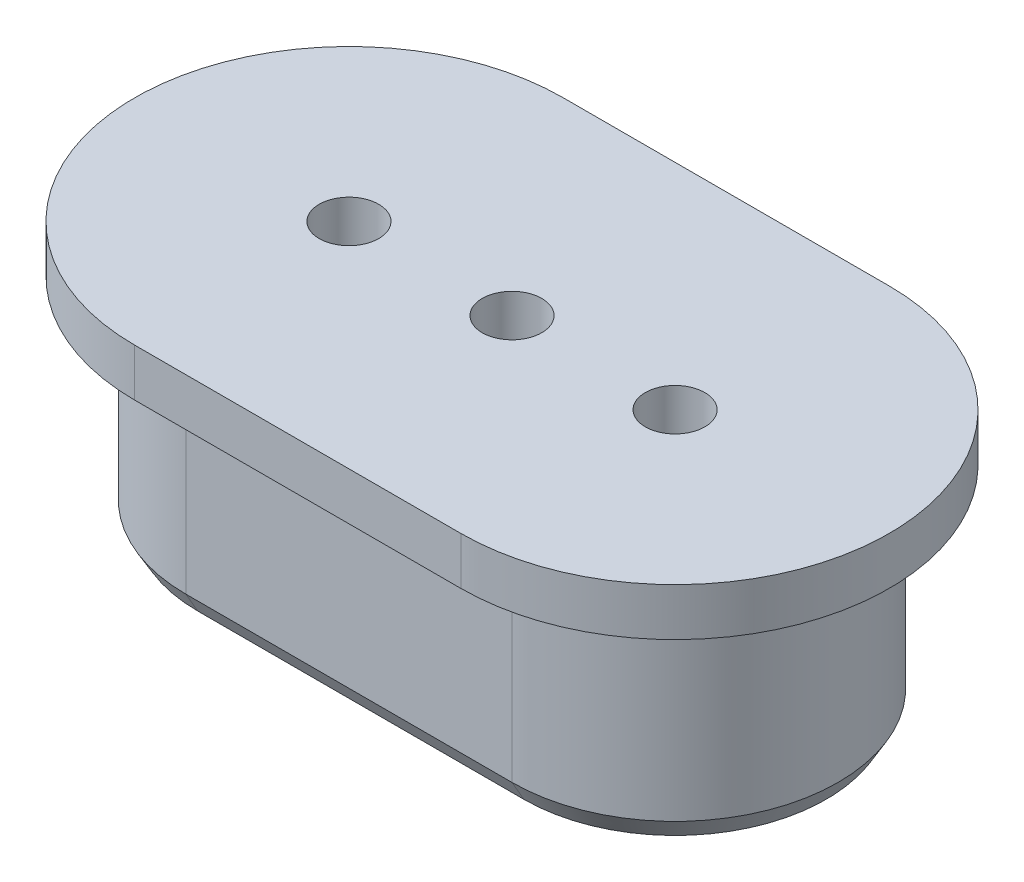
from build123d import *

# Parameters (mm, degrees)
BOSS_EXTRUDE1_DEPTH     = 4.5
SKETCH2_R               = 0.625
BOSS_EXTRUDE2_DEPTH     = 1
CHAMFER2_SIZE           = 0.25
CHAMFER2_SIZE2          = 0.433012702
SKETCH3_R               = 0.625
CUT_EXTRUDE1_DEPTH      = 1
CUT_EXTRUDE1_DEPTH_BACK = 6.5


with BuildPart() as part:
    # Sketch1 → Boss-Extrude1 (new body)
    with BuildSketch(Plane(origin=(0, 0, 0), x_dir=(1, 0, 0), z_dir=(0, 1, 0))):
        with BuildLine():
            Line((-3.425, 3.425), (3.425, 3.425))
            ThreePointArc((3.425, 3.425), (6.85, 0), (3.425, -3.425))
            Line((3.425, -3.425), (-3.425, -3.425))
            ThreePointArc((-3.425, -3.425), (-6.85, 0), (-3.425, 3.425))
        make_face()
        with BuildLine():
            Line((-3.425, 2.925), (3.425, 2.925))
            ThreePointArc((3.425, 2.925), (6.35, 0), (3.425, -2.925))
            Line((3.425, -2.925), (-3.425, -2.925))
            ThreePointArc((-3.425, -2.925), (-6.35, 0), (-3.425, 2.925))
        make_face(mode=Mode.SUBTRACT)
    extrude(amount=BOSS_EXTRUDE1_DEPTH)

    # Sketch2 → Boss-Extrude2 (add)
    with BuildSketch(Plane(origin=(0, 4.5, 0), x_dir=(1, 0, 0), z_dir=(0, 1, 0))):
        with BuildLine():
            Line((-3.425, 4.5), (3.425, 4.5))
            ThreePointArc((3.425, 4.5), (7.925, 0), (3.425, -4.5))
            Line((3.425, -4.5), (-3.425, -4.5))
            ThreePointArc((-3.425, -4.5), (-7.925, 0), (-3.425, 4.5))
        make_face()
        with Locations((-3.425, 0)):
            Circle(SKETCH2_R, mode=Mode.SUBTRACT)
        with Locations((3.425, 0)):
            Circle(SKETCH2_R, mode=Mode.SUBTRACT)
    extrude(amount=BOSS_EXTRUDE2_DEPTH)

    # Chamfer2
    chamfer2_edges = [part.edges().sort_by_distance(p)[0] for p in [
        (0, 0, 3.425),
        (-6.85, 0, 0),
        (0, 0, -3.425),
        (6.85, 0, 0),
    ]]
    chamfer2_side = [part.faces().sort_by_distance(p)[0] for p in [
        (0, 0, -3.271829344),
    ]]
    chamfer(chamfer2_edges, length=CHAMFER2_SIZE, length2=CHAMFER2_SIZE2, reference=chamfer2_side[0])

    # Sketch3 → Cut-Extrude1 (cut, two sides)
    with BuildSketch(Plane(origin=(0, 5.5, 0), x_dir=(1, 0, 0), z_dir=(0, 1, 0))) as cut_extrude1_sk:
        Circle(SKETCH3_R)
    extrude(amount=CUT_EXTRUDE1_DEPTH, mode=Mode.SUBTRACT)
    extrude(cut_extrude1_sk.sketch, amount=-CUT_EXTRUDE1_DEPTH_BACK, mode=Mode.SUBTRACT)


solid = part.part
